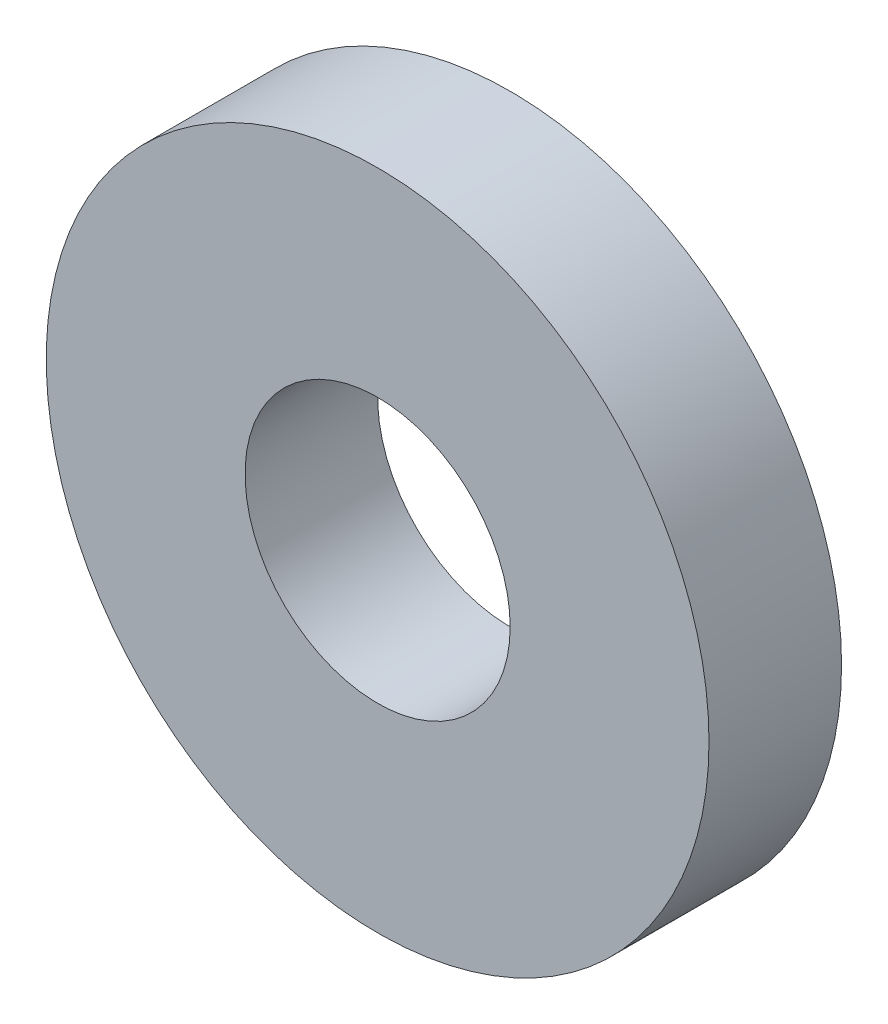
from build123d import *

# Parameters (mm, degrees)
SKETCH1_R           = 12.5
SKETCH1_R_2         = 5
BOSS_EXTRUDE1_DEPTH = 5


with BuildPart() as part:
    # Sketch1 → Boss-Extrude1 (new body)
    with BuildSketch(Plane.XY):
        with Locations((0, 92.5)):
            Circle(SKETCH1_R)
        with Locations((0, 92.5)):
            Circle(SKETCH1_R_2, mode=Mode.SUBTRACT)
    extrude(amount=BOSS_EXTRUDE1_DEPTH)


solid = part.part
